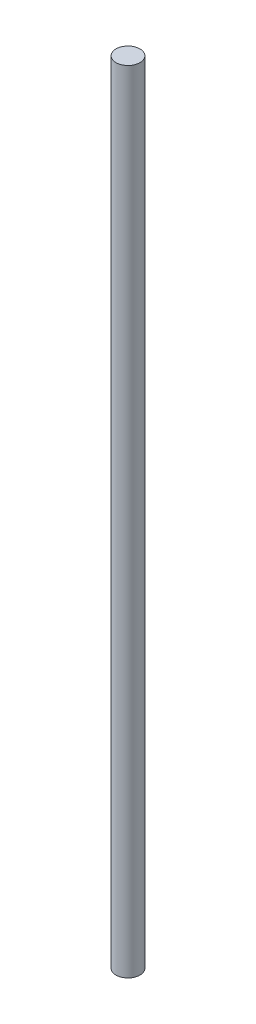
from build123d import *

# Parameters (mm, degrees)
CROQUIS1_R = 6.35


with BuildPart() as part:
    # Barrer1: sweep along a path in Croquis2
    with BuildLine(Plane.XY) as barrer1_path:
        Line((0, 0), (0, 420))
    # Croquis1 → Barrer1 (sweep)
    with BuildSketch(Plane(origin=(0, 0, 0), x_dir=(1, 0, 0), z_dir=(0, 1, 0))):
        Circle(CROQUIS1_R)
    sweep(path=barrer1_path.line)


solid = part.part
